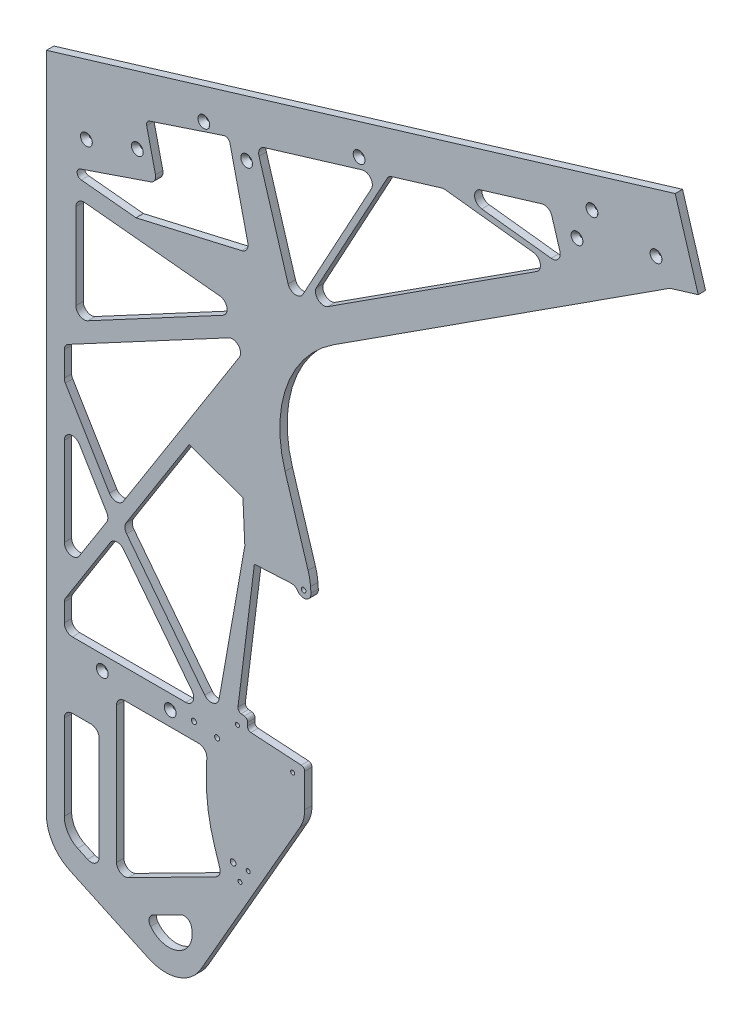
from build123d import *

# Parameters (mm, degrees)
SKETCH1_R                   = 2
BOSS_EXTRUDE1_DEPTH         = 6.35
F_8_CLEARANCE_HOLE1_D       = 4.9149
F_29_0_136_DIAMETER_HOLE1_D = 3.4544
FILLET2_R                   = 6.35
HOLE1_D                     = 3.175
HOLE1_DEPTH                 = 31.75
HOLE1_CSINK_D               = 10.16
HOLE1_CSINK_ANGLE           = 82
HOLE1_TIP                   = 0.953866233
F_6_CLEARANCE_HOLE1_D       = 4.3053
F_6_CLEARANCE_HOLE1_DEPTH   = 6.35


with BuildPart() as part:
    # Sketch1 → Boss-Extrude1 (new body)
    with BuildSketch(Plane.XY):
        with BuildLine():
            Line((81.019658058, -168.897328822), (37.70615408, -166.236789132))
            ThreePointArc((37.70615408, -166.236789132), (35.522327499, -165.170958529), (34.731784962, -162.873103898))
            Line((34.731784962, -162.873103898), (34.902859203, -160.088020532))
            ThreePointArc((34.902859203, -160.088020532), (34.176628401, -157.865217786), (32.125295873, -156.742587798))
            Line((32.125295873, -156.742587798), (29.337293116, -156.396196072))
            ThreePointArc((29.337293116, -156.396196072), (27.224016083, -155.196548795), (26.577982286, -152.85395755))
            Line((26.577982286, -152.85395755), (40.701467954, -39.178272088))
            Line((40.701467954, -39.178272088), (72.307487293, -37.567416175))
            ThreePointArc((72.307487293, -37.567416175), (75.508274508, -38.248610367), (77.944821909, -40.433170067))
            ThreePointArc((77.944821909, -40.433170067), (80.37819882, -42.616116921), (83.575051255, -43.299282101))
            ThreePointArc((83.575051255, -43.299282101), (87.915366779, -41.106021585), (89.431266941, -36.48533146))
            Line((89.431266941, -36.48533146), (89.070856204, -31.748680417))
            ThreePointArc((89.070856204, -31.748680417), (88.331558939, -26.184805765), (86.9733286, -20.738846534))
            Line((86.9733286, -20.738846534), (67.150201914, 43.21421098))
            ThreePointArc((67.150201914, 43.21421098), (68.704153469, 107.993673093), (109.099933911, 158.658990615))
            Line((109.099933911, 158.658990615), (398.624090476, 345.521584423))
            Line((398.624090476, 345.521584423), (422.935039487, 352.879420939))
            Line((422.935039487, 352.879420939), (403.099057101, 418.419278389))
            Line((403.099057101, 418.419278389), (-138.378918258, 254.538122714))
            Line((-138.378918258, 254.538122714), (-138.378918258, -315.453385964))
            ThreePointArc((-138.378918258, -315.453385964), (-132.909364503, -334.218574785), (-118.213861049, -347.106185426))
            Line((-118.213861049, -347.106185426), (-50.505892811, -378.678929533))
            ThreePointArc((-50.505892811, -378.678929533), (-25.212372145, -380.324769115), (-5.467108781, -364.431514245))
            Line((-5.467108781, -364.431514245), (80.009026118, -215.73509408))
            ThreePointArc((80.009026118, -215.73509408), (82.985089128, -208.52137789), (84, -200.784155634))
            Line((84, -200.784155634), (84, -172.066355998))
            ThreePointArc((84, -172.066355998), (83.137862332, -169.891202478), (81.019658058, -168.897328822))
        make_face()
        with Locations((83.097986954, -37.255014564)):
            Circle(SKETCH1_R, mode=Mode.SUBTRACT)
        with BuildLine():
            Line((-17.052845203, -329.494257158), (-52.060968117, -347.265819105))
            ThreePointArc((-52.060968117, -347.265819105), (-23.771187013, -359.626780553), (-17.052845203, -329.494257158))
        make_face(mode=Mode.SUBTRACT)
        with BuildLine():
            Line((-123, -235.789377226), (-123, -309.069613992))
            ThreePointArc((-123, -309.069613992), (-119.867828916, -319.815606158), (-111.452365235, -327.195769732))
            Line((-111.452365235, -327.195769732), (-102.958327832, -331.156604422))
            ThreePointArc((-102.958327832, -331.156604422), (-96.238902742, -330.716190033), (-93, -324.812449913))
            Line((-93, -324.812449913), (-93, -235.789377226))
            ThreePointArc((-93, -235.789377226), (-95.050252532, -230.839629758), (-100, -228.789377226))
            Line((-100, -228.789377226), (-116, -228.789377226))
            ThreePointArc((-116, -228.789377226), (-120.949747468, -230.839629758), (-123, -235.789377226))
        make_face(mode=Mode.SUBTRACT)
        with BuildLine():
            Line((-61.199770062, 168.179421619), (29.826630294, 189.194522014))
            ThreePointArc((29.826630294, 189.194522014), (34.188309587, 192.305677618), (35.072563367, 197.589769848))
            Line((35.072563367, 197.589769848), (19.638832994, 264.440600612))
            ThreePointArc((19.638832994, 264.440600612), (17.700947347, 267.027913965), (14.483251541, 267.337792758))
            Line((14.483251541, 267.337792758), (-49.392848873, 246.173011312))
            ThreePointArc((-49.392848873, 246.173011312), (-51.62186525, 244.335609561), (-52.032227939, 241.476210731))
            Line((-52.032227939, 241.476210731), (-43.179065741, 203.128952263))
            Line((-43.179065741, 203.128952263), (-109.246803026, 180.591656302))
            ThreePointArc((-109.246803026, 180.591656302), (-111.928836089, 176.345829111), (-108.347619238, 172.825142281))
            Line((-108.347619238, 172.825142281), (-61.199770062, 168.179421619))
        make_face(mode=Mode.SUBTRACT)
        with BuildLine():
            Line((-102.695777716, 70.621262325), (13.547329865, 132.862172762))
            ThreePointArc((13.547329865, 132.862172762), (17.10814199, 140.401199203), (10.929529426, 145.999506934))
            Line((10.929529426, 145.999506934), (-105.313578156, 157.453539643))
            ThreePointArc((-105.313578156, 157.453539643), (-110.700800309, 155.67403602), (-113, 150.487276294))
            Line((-113, 150.487276294), (-113, 76.792333148))
            ThreePointArc((-113, 76.792333148), (-109.596556966, 70.786937408), (-102.695777716, 70.621262325))
        make_face(mode=Mode.SUBTRACT)
        with BuildLine():
            Line((-123, -28.654884494), (-123, -104.746758641))
            ThreePointArc((-123, -104.746758641), (-117.95351244, -111.468647449), (-110.090345958, -108.498556757))
            Line((-110.090345958, -108.498556757), (-86.579188082, -71.464898525))
            ThreePointArc((-86.579188082, -71.464898525), (-85.489337935, -67.796413702), (-86.491561629, -64.103027464))
            Line((-86.491561629, -64.103027464), (-110.002719505, -25.044811549))
            ThreePointArc((-110.002719505, -25.044811549), (-117.87337083, -21.91022129), (-123, -28.654884494))
        make_face(mode=Mode.SUBTRACT)
        with BuildLine():
            Line((-78, -203.789377226), (-78, -320.992945508))
            ThreePointArc((-78, -320.992945508), (-74.661956673, -326.958687149), (-67.831407622, -327.234741912))
            Line((-67.831407622, -327.234741912), (7.408132297, -289.040059271))
            ThreePointArc((7.408132297, -289.040059271), (10.698904711, -285.495781445), (10.90617564, -280.663791466))
            Line((10.90617564, -280.663791466), (6.494444344, -266.884545968))
            ThreePointArc((6.494444344, -266.884545968), (0.856780444, -242.347035927), (-0.59748893, -217.212244226))
            Line((-0.59748893, -217.212244226), (-0.250179597, -203.972946573))
            ThreePointArc((-0.250179597, -203.972946573), (-2.23354318, -198.904962493), (-7.247772204, -196.789377226))
            Line((-7.247772204, -196.789377226), (-71, -196.789377226))
            ThreePointArc((-71, -196.789377226), (-75.949747468, -198.839629758), (-78, -203.789377226))
        make_face(mode=Mode.SUBTRACT)
        with BuildLine():
            Line((-15.470800679, 21.883932686), (-69.688252467, -63.516820026))
            ThreePointArc((-69.688252467, -63.516820026), (-70.770838401, -67.598133112), (-69.309232347, -71.559549091))
            Line((-69.309232347, -71.559549091), (-2.107117722, -158.177185032))
            ThreePointArc((-2.107117722, -158.177185032), (5.104316904, -160.681466294), (10.316757622, -155.104130392))
            Line((10.316757622, -155.104130392), (32.484613968, -29.632943931))
            Line((32.484613968, -29.632943931), (30.845296938, 5.564557689))
            Line((30.845296938, 5.564557689), (-15.470800679, 21.883932686))
        make_face(mode=Mode.SUBTRACT)
        with BuildLine():
            Line((-83.358453873, -85.049471439), (-123, -147.490950451))
            Line((-123, -147.490950451), (-123, -164.789377226))
            ThreePointArc((-123, -164.789377226), (-120.949747468, -169.739124694), (-116, -171.789377226))
            Line((-116, -171.789377226), (-18.493582843, -171.789377226))
            ThreePointArc((-18.493582843, -171.789377226), (-12.207227911, -167.868620912), (-12.96294892, -160.498446277))
            Line((-12.96294892, -160.498446277), (-71.918165908, -84.510338605))
            ThreePointArc((-71.918165908, -84.510338605), (-77.778314802, -81.809029579), (-83.358453873, -85.049471439))
        make_face(mode=Mode.SUBTRACT)
        with BuildLine():
            Line((18.511705321, 118.505409967), (-123, 42.734746572))
            Line((-123, 42.734746572), (-123, 15.937279137))
            Line((-123, 15.937279137), (-84.107110781, -48.674037444))
            ThreePointArc((-84.107110781, -48.674037444), (-78.19314358, -52.063468688), (-72.200176244, -48.815762615))
            Line((-72.200176244, -48.815762615), (27.725581647, 108.582541028))
            ThreePointArc((27.725581647, 108.582541028), (26.945537791, 117.097436807), (18.511705321, 118.505409967))
        make_face(mode=Mode.SUBTRACT)
        with BuildLine():
            Line((236.55061974, 323.649776269), (296.321562944, 316.742770836))
            ThreePointArc((296.321562944, 316.742770836), (302.497167394, 319.208610524), (303.824943291, 325.724396498))
            Line((303.824943291, 325.724396498), (296.893445901, 348.624831151))
            ThreePointArc((296.893445901, 348.624831151), (293.497171214, 352.7683627), (288.165723096, 353.296753095))
            Line((288.165723096, 353.296753095), (235.326277282, 337.303323874))
            ThreePointArc((235.326277282, 337.303323874), (230.38215292, 329.978305308), (236.55061974, 323.649776269))
        make_face(mode=Mode.SUBTRACT)
        with BuildLine():
            Line((104.123887079, 184.645888182), (283.866191841, 300.659579208))
            ThreePointArc((283.866191841, 300.659579208), (286.887290545, 308.13032685), (280.873685483, 313.494621944))
            Line((280.873685483, 313.494621944), (203.475200181, 322.438629347))
            Line((203.475200181, 322.438629347), (156.4343015, 308.200302809))
            Line((156.4343015, 308.200302809), (94.180176407, 193.874808481))
            ThreePointArc((94.180176407, 193.874808481), (95.565919036, 185.396487117), (104.123887079, 184.645888182))
        make_face(mode=Mode.SUBTRACT)
        with BuildLine():
            Line((44.70581348, 267.068727432), (69.739941264, 184.360421397))
            ThreePointArc((69.739941264, 184.360421397), (75.724481753, 179.424962594), (82.587409979, 183.040719033))
            Line((82.587409979, 183.040719033), (141.453242141, 291.143842337))
            ThreePointArc((141.453242141, 291.143842337), (140.735215006, 298.909502995), (133.27769537, 301.191267506))
            Line((133.27769537, 301.191267506), (49.377735423, 275.796450237))
            ThreePointArc((49.377735423, 275.796450237), (45.234203874, 272.40017555), (44.70581348, 267.068727432))
        make_face(mode=Mode.SUBTRACT)
    extrude(amount=BOSS_EXTRUDE1_DEPTH)

    # #8 Clearance Hole1 (through all)
    with Locations(Plane.XY.offset(6.35)):
        with Locations((22.417305887, -270.769233836)):
            Hole(F_8_CLEARANCE_HOLE1_D / 2)

    # #29 (0.136) Diameter Hole1 (through all)
    with Locations(Plane.XY.offset(6.35)):
        with Locations((28.303582289, -282.335622674), (35.395348907, -270.769233836), (26.084910743, -166.378822149), (73.686163127, -178.091324216)):
            Hole(F_29_0_136_DIAMETER_HOLE1_D / 2)

    # Fillet2
    fillet2_edges = [part.edges().sort_by_distance(p)[0] for p in [
        (-43.179065741, 203.128952263, 3.175),
        (-123, -147.490950451, 3.175),
        (-123, 42.734746572, 3.175),
        (-123, 15.937279137, 3.175),
        (203.475200181, 322.438629347, 3.175),
        (156.4343015, 308.200302809, 3.175),
        (-52.060968117, -347.265819105, 3.175),
        (-17.052845203, -329.494257158, 3.175),
    ]]
    fillet(fillet2_edges, radius=FILLET2_R)

    # Hole1
    with Locations(Plane(origin=(-277.286738577, -215.287141225, 6.35), x_dir=(-0.089959629, -0.995945413, 0), z_dir=(0, 0, 1))):
        with Locations((-507.038658285, 229.776136946), (-559.371199386, 359.303721429), (-637.870011036, 553.595098153), (-636.071223534, 609.111420407), (-609.449424187, 543.22015483), (-499.723341091, 267.496267453), (-453.103621196, 177.188747915), (-434.459074831, 134.806234549), (-52.960474705, 241.752641108), (-47.697836423, 183.489834462)):
            CounterSinkHole(HOLE1_D / 2, HOLE1_CSINK_D / 2, depth=HOLE1_DEPTH, counter_sink_angle=HOLE1_CSINK_ANGLE)
            with Locations((0, 0, -(HOLE1_DEPTH + HOLE1_TIP / 2))):  # 118° drill point
                Cone(0, HOLE1_D / 2, HOLE1_TIP, mode=Mode.SUBTRACT)

    # #6 Clearance Hole1
    with Locations(Plane.XY.offset(6.35)):
        with Locations((8.603760686, -184.73043846), (-11.359669796, -182.481960161)):
            Hole(F_6_CLEARANCE_HOLE1_D / 2, depth=F_6_CLEARANCE_HOLE1_DEPTH)


solid = part.part
